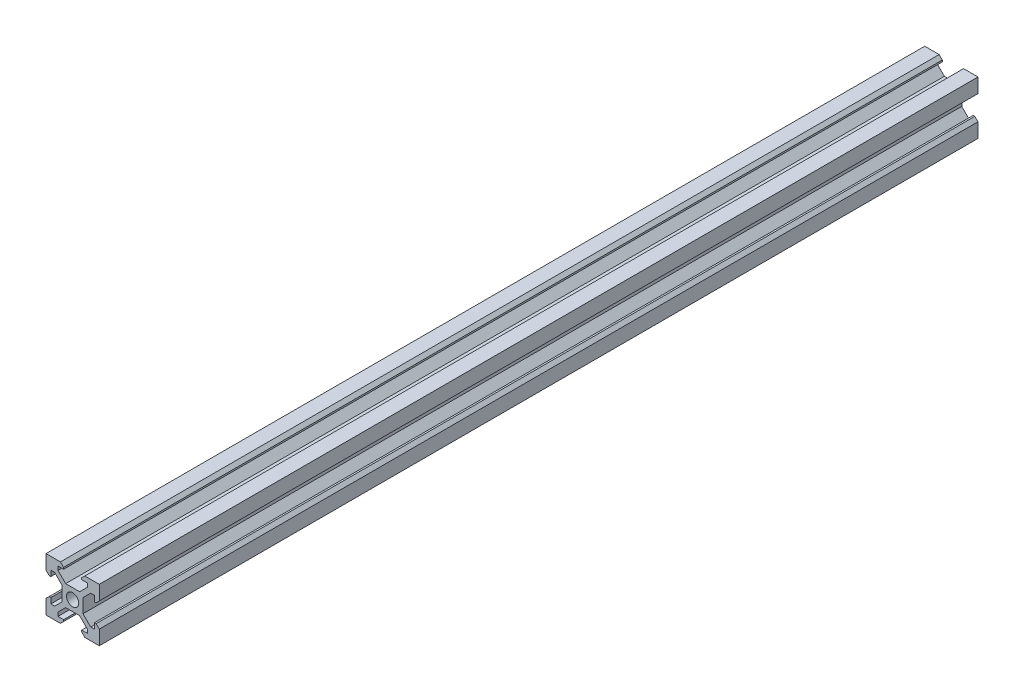
from build123d import *

# Parameters (mm, degrees)
SKETCH1_W           = 20
SKETCH1_H           = 20
BOSS_EXTRUDE1_DEPTH = 330
SKETCH2_R           = 2.3
CUT_EXTRUDE1_DEPTH  = 331


with BuildPart() as part:
    # Sketch1 → Boss-Extrude1 (new body)
    with BuildSketch(Plane.XY):
        with Locations((10, 10)):
            Rectangle(SKETCH1_W, SKETCH1_H)
    extrude(amount=-BOSS_EXTRUDE1_DEPTH)

    # Sketch2 → Cut-Extrude1 (cut, through all)
    with BuildSketch(Plane.XY):
        with Locations((10, 10)):
            Circle(SKETCH2_R)
        Polygon((5.42, 20), (14.58, 20), (13.395, 18.815), (13.395, 18.2), (15.5, 18.2), (15.5, 16.772792206), (12.627207794, 13.9), (7.372792206, 13.9), (4.5, 16.772792206), (4.5, 18.2), (6.605, 18.2), (6.605, 18.815), align=None)
        Polygon((6.605, 1.185), (5.42, 0), (14.58, 0), (13.395, 1.185), (13.395, 1.8), (15.5, 1.8), (15.5, 3.227207794), (12.627207794, 6.1), (7.372792206, 6.1), (4.5, 3.227207794), (4.5, 1.8), (6.605, 1.8), align=None)
        Polygon((1.8, 6.605), (1.185, 6.605), (0, 5.42), (0, 14.58), (1.185, 13.395), (1.8, 13.395), (1.8, 15.5), (3.227207794, 15.5), (6.1, 12.627207794), (6.1, 7.372792206), (3.227207794, 4.5), (1.8, 4.5), align=None)
        Polygon((18.815, 6.605), (20, 5.42), (20, 14.58), (18.815, 13.395), (18.2, 13.395), (18.2, 15.5), (16.772792206, 15.5), (13.9, 12.627207794), (13.9, 7.372792206), (16.772792206, 4.5), (18.2, 4.5), (18.2, 6.605), align=None)
    extrude(amount=-CUT_EXTRUDE1_DEPTH, mode=Mode.SUBTRACT)


solid = part.part
